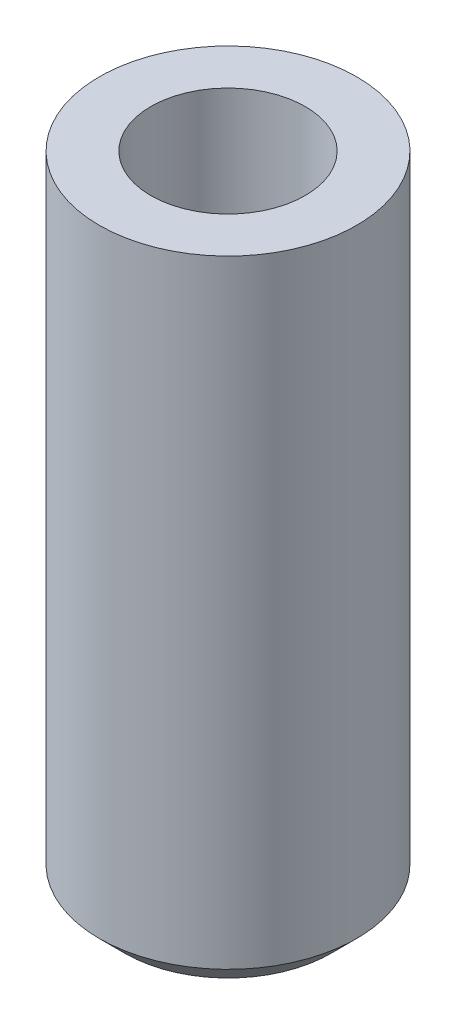
from build123d import *

# Parameters (mm, degrees)
F_6_0_6_DIAMETER_HOLE1_D     = 6
F_6_0_6_DIAMETER_HOLE1_DEPTH = 20
F_6_0_6_DIAMETER_HOLE1_TIP   = 1.802581857
SKETCH16_R                   = 1.5
CUT_EXTRUDE5_DEPTH           = 26


with BuildPart() as part:
    # Sketch3 → Revolve1 (revolve)
    with BuildSketch(Plane.XY):
        Polygon((0, 0), (4, 0), (5, 1), (5, 25), (0, 25), align=None)
    revolve(axis=Axis((0, 31.444228921, 0), (0, -1, 0)))

    # Ø6.0 (6) Diameter Hole1
    with Locations(Plane(origin=(0, 25, 0), x_dir=(1, 0, 0), z_dir=(0, 1, 0))):
        with Locations((0, 0)):
            Hole(F_6_0_6_DIAMETER_HOLE1_D / 2, depth=F_6_0_6_DIAMETER_HOLE1_DEPTH)
            with Locations((0, 0, -(F_6_0_6_DIAMETER_HOLE1_DEPTH + F_6_0_6_DIAMETER_HOLE1_TIP / 2))):  # 118° drill point
                Cone(0, F_6_0_6_DIAMETER_HOLE1_D / 2, F_6_0_6_DIAMETER_HOLE1_TIP, mode=Mode.SUBTRACT)

    # Sketch16 → Cut-Extrude5 (cut, through all)
    with BuildSketch(Plane(origin=(0, 25, 0), x_dir=(1, 0, 0), z_dir=(0, 1, 0))):
        Circle(SKETCH16_R)
    extrude(amount=-CUT_EXTRUDE5_DEPTH, mode=Mode.SUBTRACT)


solid = part.part
